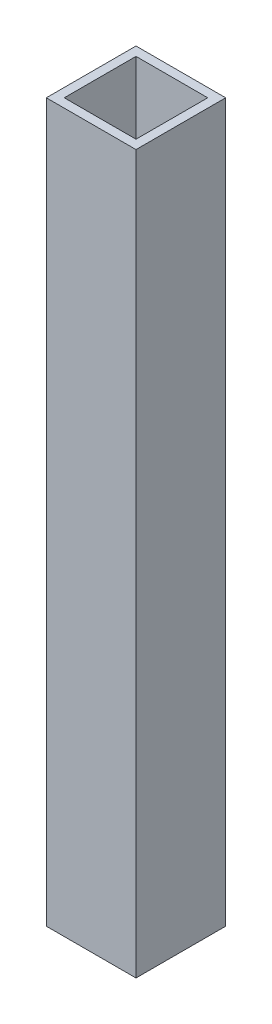
from build123d import *

# Parameters (mm, degrees)
SKETCH_1_W      = 10
SKETCH_1_H      = 10
SKETCH_1_W_2    = 8
SKETCH_1_H_2    = 8
EXTRUDE_1_DEPTH = 80


with BuildPart() as part:
    # 草图1 → 凸台-拉伸1 (new body)
    with BuildSketch(Plane.XZ.offset(80)):
        with Locations((20, 0)):
            Rectangle(SKETCH_1_W, SKETCH_1_H)
        with Locations((20, 0)):
            Rectangle(SKETCH_1_W_2, SKETCH_1_H_2, mode=Mode.SUBTRACT)
    extrude(amount=-EXTRUDE_1_DEPTH)


solid = part.part
